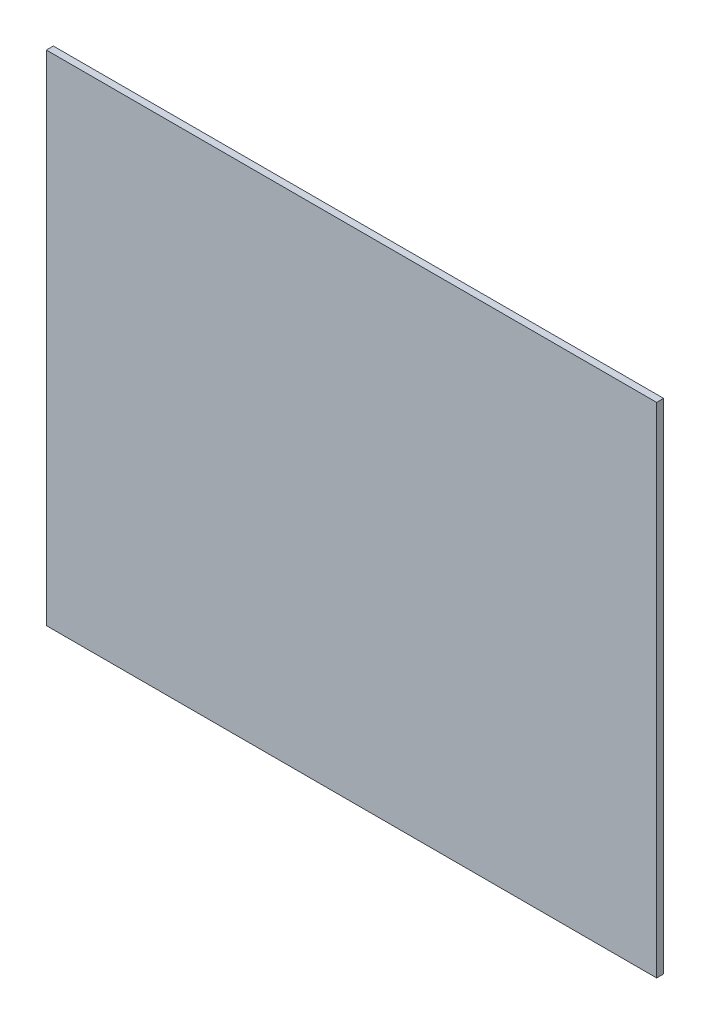
from build123d import *

# Parameters (mm, degrees)
CROQUIS1_W              = 131
CROQUIS1_H              = 107
SALIENTE_EXTRUIR1_DEPTH = 1.5


with BuildPart() as part:
    # Croquis1 → Saliente-Extruir1 (new body)
    with BuildSketch(Plane.XY):
        with Locations((10.464475059, -16.940687004)):
            Rectangle(CROQUIS1_W, CROQUIS1_H)
    extrude(amount=SALIENTE_EXTRUIR1_DEPTH)


solid = part.part
